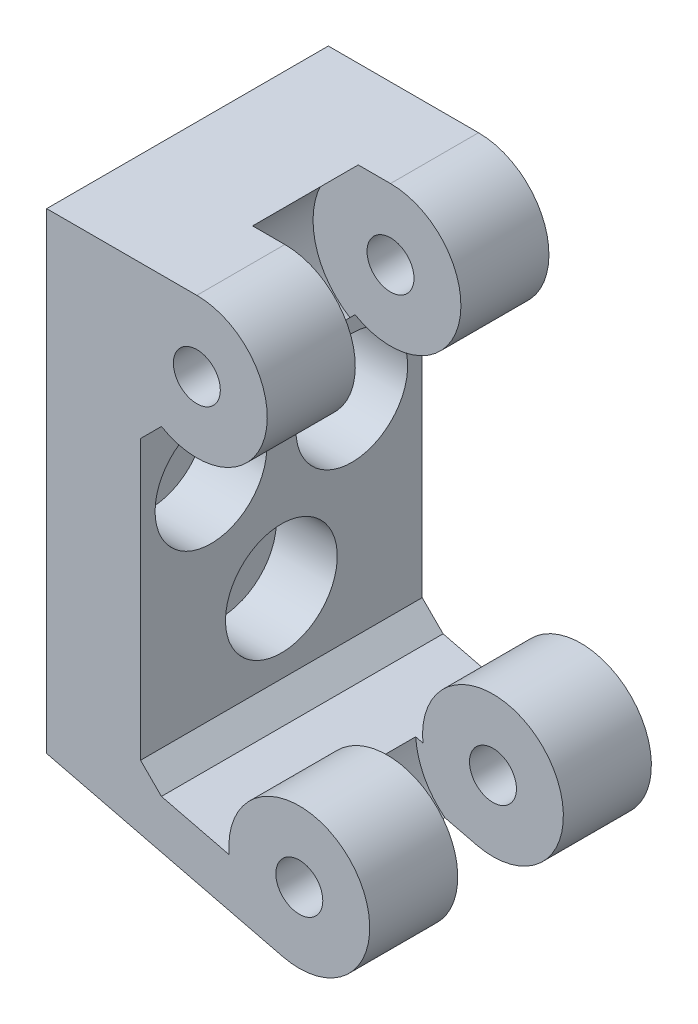
from build123d import *

# Parameters (mm, degrees)
SKETCH_OPTIMIZATION_PARAMETERS_R = 1
BOSS_EXTRUDE1_DEPTH              = 12
SKETCH2_R                        = 3.3
CUT_EXTRUDE1_DEPTH               = 2.25
CUT_EXTRUDE1_DEPTH_BACK          = 2.25
HOLE_SKETCH_R                    = 1.288405797
SCREW_SHAFT_HOLES_DEPTH          = 5
SCREW_SHAFT_HOLES_DEPTH_BACK     = 10.763989156
SKETCH5_R                        = 2.38125
SCREW_COUNTERBORES_DEPTH         = 2.591836735


with BuildPart() as part:
    # Sketch-optimization parameters → Boss-Extrude1 (new body)
    with BuildSketch(Plane.XY):
        with BuildLine():
            Line((0, 0), (0, 20.103508611))
            Line((0, 20.103508611), (6.398918491, 20.103508611))
            ThreePointArc((6.398918491, 20.103508611), (9.29529716, 16.32184973), (4.889598418, 14.510835682))
            Line((4.889598418, 14.510835682), (4, 13.621237264))
            Line((4, 13.621237264), (4, 1.750446326))
            Line((4, 1.750446326), (4.889598418, 0.860847908))
            Line((4.889598418, 0.860847908), (7.778825692, 0.152757593))
            ThreePointArc((7.778825692, 0.152757593), (13.029319293, 2.417543543), (10.049883998, -2.463020336))
            Line((10.049883998, -2.463020336), (0, 0))
        make_face()
        with Locations((6.398918491, 17.103508611)):
            Circle(SKETCH_OPTIMIZATION_PARAMETERS_R, mode=Mode.SUBTRACT)
        with Locations((10.763989156, 0.450749356)):
            Circle(SKETCH_OPTIMIZATION_PARAMETERS_R, mode=Mode.SUBTRACT)
    extrude(amount=BOSS_EXTRUDE1_DEPTH)

    # Sketch2 → Cut-Extrude1 (cut, two sides)
    with BuildSketch(Plane.XY.offset(6)) as cut_extrude1_sk:
        with Locations((6.398918491, 17.103508611)):
            Circle(SKETCH2_R)
        with Locations((10.763989156, 0.450749356)):
            Circle(SKETCH2_R)
    extrude(amount=CUT_EXTRUDE1_DEPTH, mode=Mode.SUBTRACT)
    extrude(cut_extrude1_sk.sketch, amount=-CUT_EXTRUDE1_DEPTH_BACK, mode=Mode.SUBTRACT)

    # Hole sketch → Screw shaft holes (cut, two sides)
    with BuildSketch(Plane(origin=(4, 36.444645714, 0), x_dir=(0, 0, -1), z_dir=(-1, 0, 0))) as screw_shaft_holes_sk:
        with Locations((-9, 25.823408449)):
            Circle(HOLE_SKETCH_R)
        with Locations((-3, 25.823408449)):
            Circle(HOLE_SKETCH_R)
        with Locations((-6, 31.355067842)):
            Circle(HOLE_SKETCH_R)
    extrude(amount=SCREW_SHAFT_HOLES_DEPTH, mode=Mode.SUBTRACT)
    extrude(screw_shaft_holes_sk.sketch, amount=-SCREW_SHAFT_HOLES_DEPTH_BACK, mode=Mode.SUBTRACT)

    # Sketch5 → Screw counterbores (cut)
    with BuildSketch(Plane(origin=(4, 26.197134063, 0), x_dir=(0, 0, -1), z_dir=(-1, 0, 0))):
        with Locations((-6, 21.107556192)):
            Circle(SKETCH5_R)
        with Locations((-9, 15.575896799)):
            Circle(SKETCH5_R)
        with Locations((-3, 15.575896799)):
            Circle(SKETCH5_R)
    extrude(amount=SCREW_COUNTERBORES_DEPTH, mode=Mode.SUBTRACT)


solid = part.part
